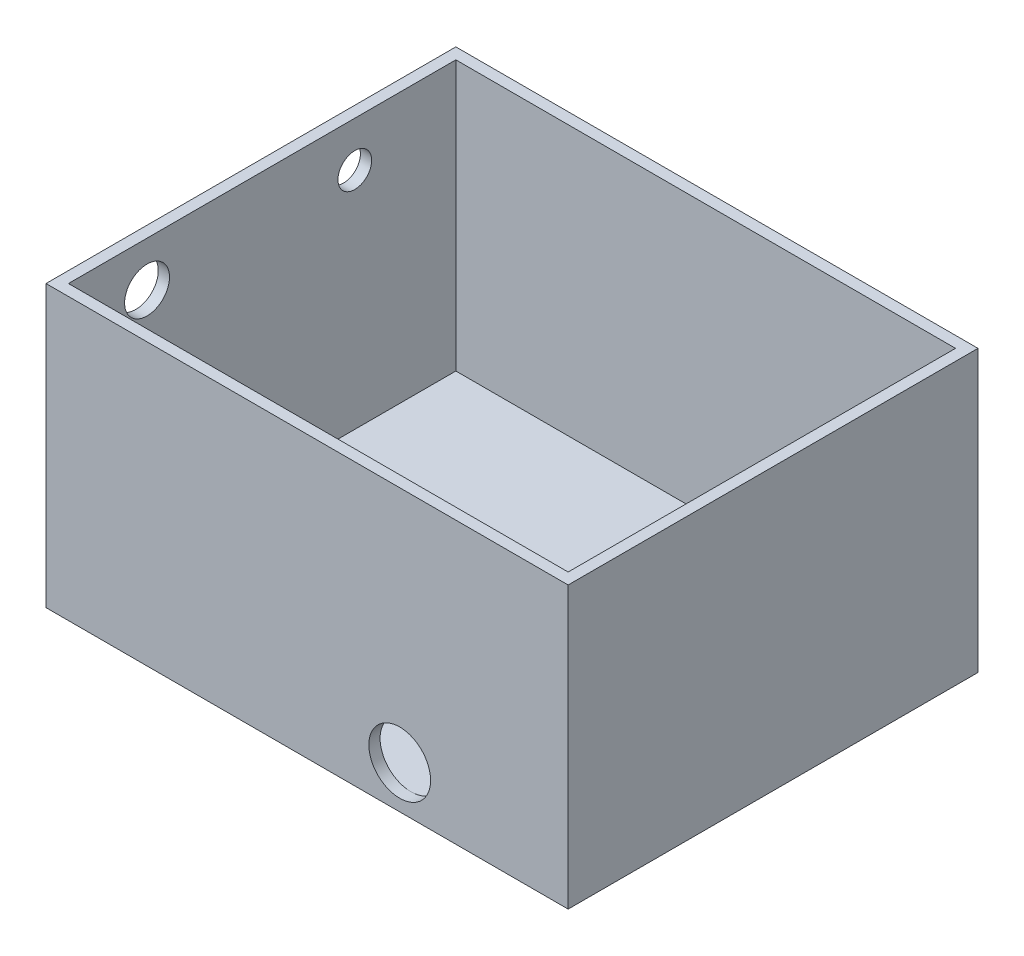
from build123d import *

# Parameters (mm, degrees)
SKETCH2_W           = 118.11
SKETCH2_H           = 92.71
BOSS_EXTRUDE2_DEPTH = 63.5
SHELL1_T            = -2.54
SKETCH3_R           = 6.985
CUT_EXTRUDE1_DEPTH  = 90.17
CUT_EXTRUDE2_REACH  = 120.11
SKETCH4_R           = 5.08
CUT_EXTRUDE3_REACH  = 120.11
SKETCH5_R           = 3.81


with BuildPart() as part:
    # Sketch2 → Boss-Extrude2 (new body)
    with BuildSketch(Plane(origin=(0, 0, 0), x_dir=(1, 0, 0), z_dir=(0, 1, 0))):
        Rectangle(SKETCH2_W, SKETCH2_H)
    extrude(amount=BOSS_EXTRUDE2_DEPTH)

    # Shell1
    shell1_openings = [part.faces().sort_by_distance(p)[0] for p in [
        (0, 63.5, 0),
    ]]
    offset(amount=SHELL1_T, openings=shell1_openings, kind=Kind.INTERSECTION)

    # Sketch3 → Cut-Extrude1 (cut)
    with BuildSketch(Plane.XY.offset(46.355)):
        with Locations((20.955, 9.652)):
            Circle(SKETCH3_R)
    extrude(amount=-CUT_EXTRUDE1_DEPTH, mode=Mode.SUBTRACT)

    # Sketch4 → Cut-Extrude2 (cut, up to next)
    with BuildSketch(Plane.ZY.offset(59.055), mode=Mode.PRIVATE) as cut_extrude2_sk1:
        with Locations((26.035, 53.34)):
            Circle(SKETCH4_R)
    cut_extrude2_tool1 = extrude(cut_extrude2_sk1.sketch, amount=-CUT_EXTRUDE2_REACH, mode=Mode.PRIVATE) & part.part
    add(cut_extrude2_tool1.solids().sort_by_distance((-59.055, 53.34, 26.035))[0], mode=Mode.SUBTRACT)

    # Sketch5 → Cut-Extrude3 (cut, up to next)
    with BuildSketch(Plane.ZY.offset(59.055), mode=Mode.PRIVATE) as cut_extrude3_sk1:
        with Locations((-20.955, 53.34)):
            Circle(SKETCH5_R)
    cut_extrude3_tool1 = extrude(cut_extrude3_sk1.sketch, amount=-CUT_EXTRUDE3_REACH, mode=Mode.PRIVATE) & part.part
    add(cut_extrude3_tool1.solids().sort_by_distance((-59.055, 53.34, -20.955))[0], mode=Mode.SUBTRACT)


solid = part.part
